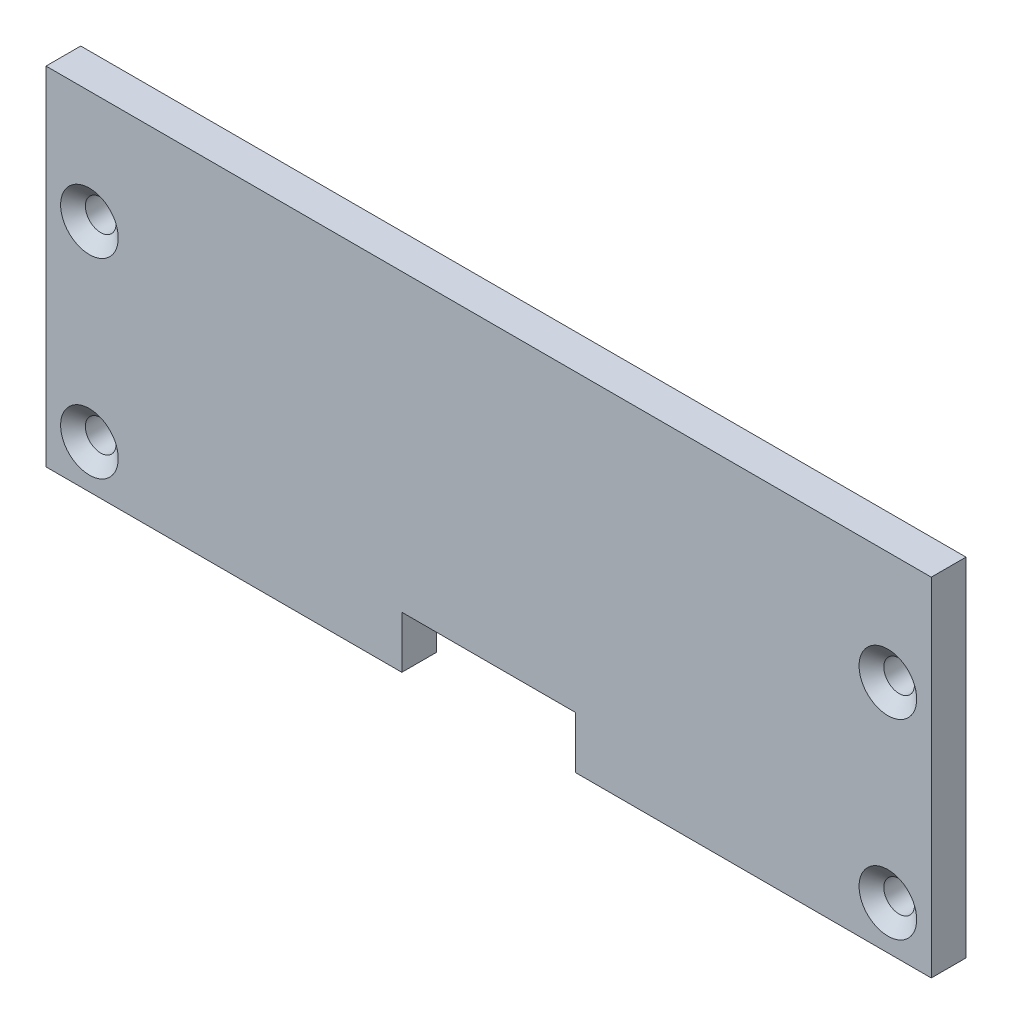
from build123d import *

# Parameters (mm, degrees)
SKETCH1_W                                         = 129.54
SKETCH1_H                                         = 50.8
BOSS_EXTRUDE1_DEPTH                               = 5.08
CSK_FOR_8_FLAT_HEAD_MACHINE_SCREW_100_D           = 4.4958
CSK_FOR_8_FLAT_HEAD_MACHINE_SCREW_100_CSINK_D     = 8.4328
CSK_FOR_8_FLAT_HEAD_MACHINE_SCREW_100_CSINK_ANGLE = 100
SKETCH5_W                                         = 25.4
SKETCH5_H                                         = 7.62
CUT_EXTRUDE1_DEPTH                                = 6.08


with BuildPart() as part:
    # Sketch1 → Boss-Extrude1 (new body)
    with BuildSketch(Plane.XY):
        Rectangle(SKETCH1_W, SKETCH1_H)
    extrude(amount=BOSS_EXTRUDE1_DEPTH)

    # CSK for #8 Flat Head Machine Screw (100)1 (through all)
    with Locations(Plane.XY.offset(5.08)):
        with Locations((-58.42, 8.89), (-58.42, -19.05), (58.42, -19.05), (58.42, 8.89)):
            CounterSinkHole(CSK_FOR_8_FLAT_HEAD_MACHINE_SCREW_100_D / 2, CSK_FOR_8_FLAT_HEAD_MACHINE_SCREW_100_CSINK_D / 2, counter_sink_angle=CSK_FOR_8_FLAT_HEAD_MACHINE_SCREW_100_CSINK_ANGLE)

    # Sketch5 → Cut-Extrude1 (cut, through all)
    with BuildSketch(Plane.XY.offset(5.08)):
        with Locations((0, -21.59)):
            Rectangle(SKETCH5_W, SKETCH5_H)
    extrude(amount=-CUT_EXTRUDE1_DEPTH, mode=Mode.SUBTRACT)


solid = part.part
